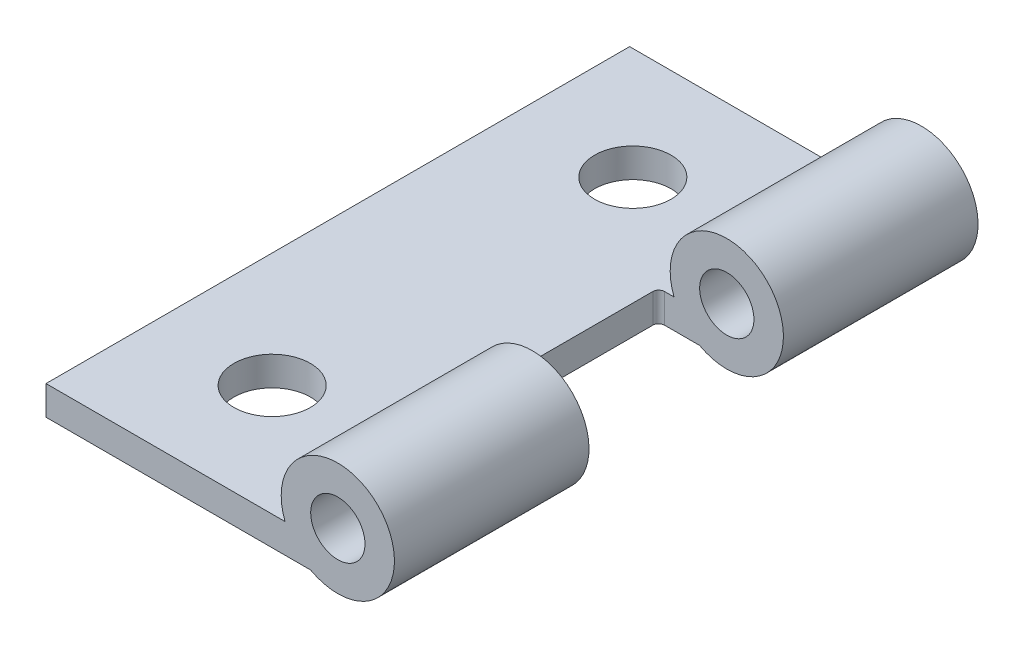
from build123d import *

# Parameters (mm, degrees)
BOSS_EXTRUDE1_DEPTH      = 12.7
BOSS_EXTRUDE1_DEPTH_BACK = 12.7
SKETCH2_R                = 1.1811
CUT_EXTRUDE1_DEPTH       = 4.23291
CUT_EXTRUDE1_DEPTH_BACK  = 4.2291
SKETCH3_R                = 2.4638
CUT_EXTRUDE2_DEPTH       = 4.2291
CUT_EXTRUDE2_DEPTH_BACK  = 4.2291
SKETCH4_W                = 2.905794066
SKETCH4_H                = 2.259273031
FILLET2_R                = 0.254
FILLET3_R                = 0.254
SKETCH5_R                = 1.6637
CUT_EXTRUDE3_DEPTH       = 2.54


with BuildPart() as part:
    # Sketch2 → Boss-Extrude1 (new, two sides: drawn at the far end of the back side and taken through both)
    with BuildSketch(Plane.XY.offset(-BOSS_EXTRUDE1_DEPTH_BACK)):
        with BuildLine():
            Line((-17.6276, 2.614576368), (-17.6276, 3.884576368))
            Line((-17.6276, 3.884576368), (-7.224163794, 3.884576368))
            ThreePointArc((-7.224163794, 3.884576368), (-3.076448638, 6.402723098), (-6.1087, 2.614576368))
            Line((-6.1087, 2.614576368), (-17.6276, 2.614576368))
        make_face()
        with Locations((-4.9276, 4.776823632)):
            Circle(SKETCH2_R, mode=Mode.SUBTRACT)
    extrude(amount=BOSS_EXTRUDE1_DEPTH + BOSS_EXTRUDE1_DEPTH_BACK)

    # Sketch3 → Cut-Extrude1 (cut, two sides: drawn at the far end of the back side and taken through both)
    with BuildSketch(Plane.XY.offset(-CUT_EXTRUDE1_DEPTH_BACK)):
        with Locations((-4.9276, 4.776823632)):
            Circle(SKETCH3_R)
    extrude(amount=CUT_EXTRUDE1_DEPTH + CUT_EXTRUDE1_DEPTH_BACK, mode=Mode.SUBTRACT)

    # Sketch4 → Cut-Extrude2 (cut, two sides: drawn at the far end of the back side and taken through both)
    with BuildSketch(Plane.XY.offset(-CUT_EXTRUDE2_DEPTH_BACK)):
        with Locations((-6.438882967, 3.744212884)):
            Rectangle(SKETCH4_W, SKETCH4_H)
    extrude(amount=CUT_EXTRUDE2_DEPTH + CUT_EXTRUDE2_DEPTH_BACK, mode=Mode.SUBTRACT)

    # Fillet2
    fillet2_edges = [part.edges().sort_by_distance(p)[0] for p in [
        (-7.89178, 3.249576368, -4.2291),
    ]]
    fillet(fillet2_edges, radius=FILLET2_R)

    # Fillet3
    fillet3_edges = [part.edges().sort_by_distance(p)[0] for p in [
        (-7.89178, 3.249576368, 4.2291),
    ]]
    fillet(fillet3_edges, radius=FILLET3_R)

    # Sketch5 → Cut-Extrude3 (cut)
    with BuildSketch(Plane(origin=(0, 3.884576368, 0), x_dir=(1, 0, 0), z_dir=(0, 1, 0))):
        with Locations((-12.6365, 7.8486)):
            Circle(SKETCH5_R)
        with Locations((-12.6365, -7.8486)):
            Circle(SKETCH5_R)
    extrude(amount=-CUT_EXTRUDE3_DEPTH, mode=Mode.SUBTRACT)


solid = part.part
